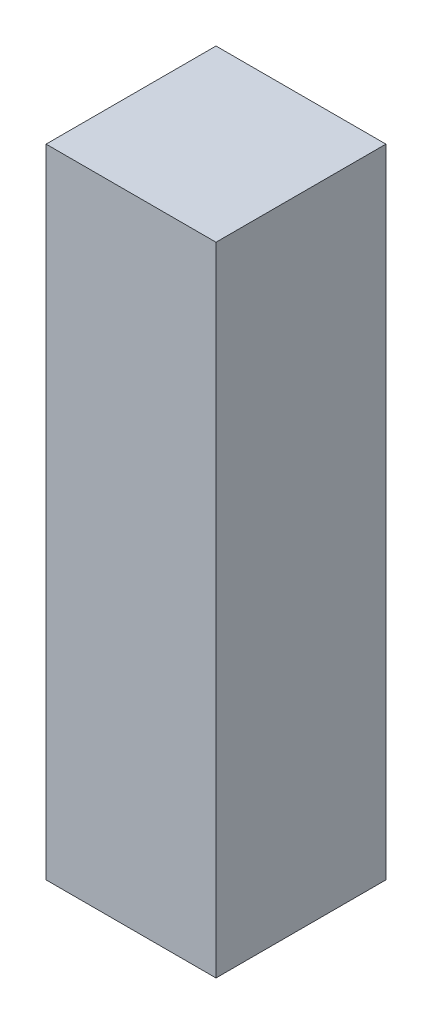
from build123d import *

# Parameters (mm, degrees)
SKETCH2_W           = 0.8
SKETCH2_H           = 0.8
BOSS_EXTRUDE1_DEPTH = 3


with BuildPart() as part:
    # Sketch2 → Boss-Extrude1 (new body)
    with BuildSketch(Plane(origin=(0, 0, 0), x_dir=(1, 0, 0), z_dir=(0, 1, 0))):
        with Locations((0.4, 0.4)):
            Rectangle(SKETCH2_W, SKETCH2_H)
    extrude(amount=BOSS_EXTRUDE1_DEPTH)


solid = part.part
